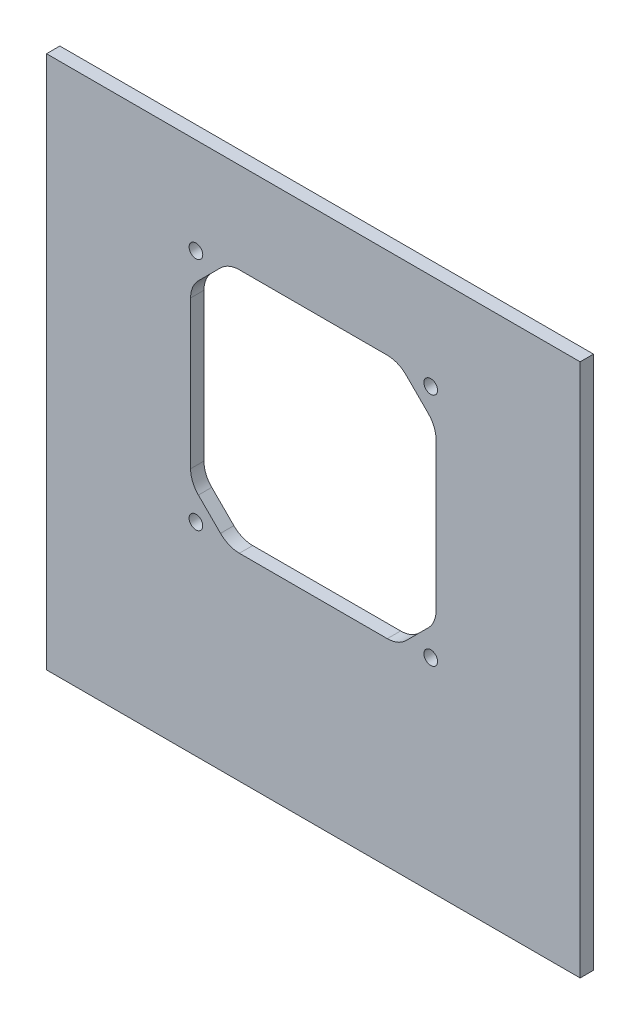
from build123d import *

# Parameters (mm, degrees)
SKETCH2_W           = 254
SKETCH2_H           = 254
BOSS_EXTRUDE1_DEPTH = 6.35
SKETCH3_R           = 3.25
CUT_EXTRUDE1_DEPTH  = 6.35


with BuildPart() as part:
    # Sketch2 → Boss-Extrude1 (new body)
    with BuildSketch(Plane.XY):
        with Locations((127, 127)):
            Rectangle(SKETCH2_W, SKETCH2_H)
    extrude(amount=BOSS_EXTRUDE1_DEPTH)

    # Sketch3 → Cut-Extrude1 (cut)
    with BuildSketch(Plane.XY.offset(6.35)):
        with Locations((71.12, 208.28)):
            Circle(SKETCH3_R)
        with Locations((182.88, 208.28)):
            Circle(SKETCH3_R)
        with Locations((182.88, 96.52)):
            Circle(SKETCH3_R)
        with Locations((71.12, 96.52)):
            Circle(SKETCH3_R)
        with BuildLine():
            Line((72.299743879, 196.579231637), (82.820768363, 207.100256121))
            ThreePointArc((82.820768363, 207.100256121), (86.940944893, 209.853270063), (91.801024484, 210.82))
            Line((91.801024484, 210.82), (162.198975516, 210.82))
            ThreePointArc((162.198975516, 210.82), (167.059055107, 209.853270063), (171.179231637, 207.100256121))
            Line((171.179231637, 207.100256121), (181.700256121, 196.579231637))
            ThreePointArc((181.700256121, 196.579231637), (184.453270063, 192.459055107), (185.42, 187.598975516))
            Line((185.42, 187.598975516), (185.42, 117.201024484))
            ThreePointArc((185.42, 117.201024484), (184.453270063, 112.340944893), (181.700256121, 108.220768363))
            Line((181.700256121, 108.220768363), (171.179231637, 97.699743879))
            ThreePointArc((171.179231637, 97.699743879), (167.059055107, 94.946729937), (162.198975516, 93.98))
            Line((162.198975516, 93.98), (91.801024484, 93.98))
            ThreePointArc((91.801024484, 93.98), (86.940944893, 94.946729937), (82.820768363, 97.699743879))
            Line((82.820768363, 97.699743879), (72.299743879, 108.220768363))
            ThreePointArc((72.299743879, 108.220768363), (69.546729937, 112.340944893), (68.58, 117.201024484))
            Line((68.58, 117.201024484), (68.58, 187.598975516))
            ThreePointArc((68.58, 187.598975516), (69.546729937, 192.459055107), (72.299743879, 196.579231637))
        make_face()
    extrude(amount=-CUT_EXTRUDE1_DEPTH, mode=Mode.SUBTRACT)


solid = part.part
